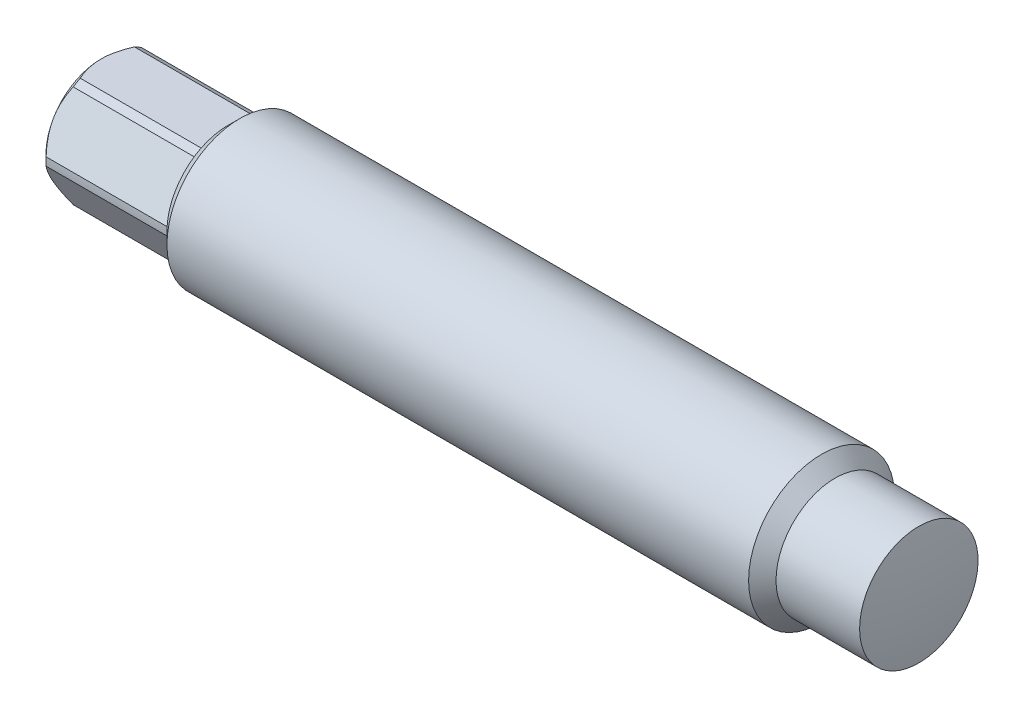
from build123d import *

# Parameters (mm, degrees)
SKETCH1_OUTSIDE_W  = 42.92
SKETCH1_OUTSIDE_H  = 42.92
CUT_EXTRUDE1_DEPTH = 17.51


with BuildPart() as part:
    # Sketch1 w/mock PCB → Revolve1 (revolve)
    with BuildSketch(Plane.XY, mode=Mode.PRIVATE) as revolve1_sk:
        with BuildLine():
            Line((0, 0), (-106.68, 0))
            Line((-106.68, 0), (-106.68, 7.14375))
            Line((-106.68, 7.14375), (-105.86085, 7.9629))
            Line((-105.86085, 7.9629), (-90.17, 7.9629))
            Line((-90.17, 7.9629), (-88.6714, 9.4615))
            Line((-88.6714, 9.4615), (-13.208, 9.4615))
            Line((-13.208, 9.4615), (-11.43, 7.6835))
            Line((-11.43, 7.6835), (-0.584426442, 7.6835))
            ThreePointArc((-0.584426442, 7.6835), (-0.146317327, 3.852847211), (0, 0))
        make_face()
    revolve(revolve1_sk.sketch.rotate(Axis((0, 0, 0), (1, 0, 0)), 90), axis=Axis((0, 0, 0), (1, 0, 0)))  # turned: the seam where the file's is

    # Sketch1 outside → Cut-Extrude1 (cut, through all)
    with BuildSketch(Plane(origin=(-90.17, 0, 0), x_dir=(0, 0, -1), z_dir=(1, 0, 0))):
        Rectangle(SKETCH1_OUTSIDE_W, SKETCH1_OUTSIDE_H)
        Polygon((4.124445986, 7.14375), (-4.124445986, 7.14375), (-8.248891971, 0), (-4.124445986, -7.14375), (4.124445986, -7.14375), (8.248891971, 0), align=None, mode=Mode.SUBTRACT)
    extrude(amount=-CUT_EXTRUDE1_DEPTH, mode=Mode.SUBTRACT)

    # Sketch2 → Cut-Revolve1 (revolve, cut)
    with BuildSketch(Plane.XY, mode=Mode.PRIVATE) as cut_revolve1_sk:
        Polygon((-98.464010462, 0), (-99.380554014, 1.5875), (-102.555554014, 1.5875), (-106.68, 3.96875), (-106.68, 0), align=None)
    revolve(cut_revolve1_sk.sketch.rotate(Axis((-106.68, 0, 0), (-1, 0, 0)), 270), axis=Axis((-106.68, 0, 0), (-1, 0, 0)), mode=Mode.SUBTRACT)  # turned: the seam where the file's is


solid = part.part
